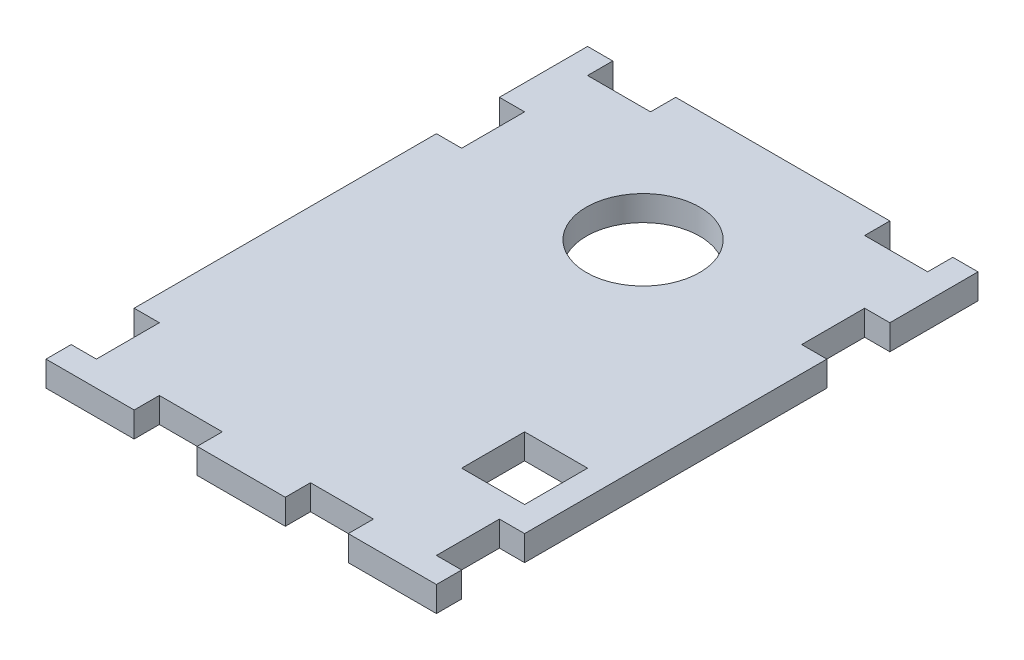
from build123d import *

# Parameters (mm, degrees)
SKETCH1_W           = 31
SKETCH1_H           = 43
BOSS_EXTRUDE1_DEPTH = 2
SKETCH2_W           = 5
SKETCH2_H           = 2
CUT_EXTRUDE1_DEPTH  = 2
SKETCH3_R           = 4.5
SKETCH3_W           = 5
SKETCH3_H           = 5
SKETCH3_W_2         = 2
SKETCH3_H_2         = 2
CUT_EXTRUDE2_DEPTH  = 2


with BuildPart() as part:
    # Sketch1 → Boss-Extrude1 (new body)
    with BuildSketch(Plane(origin=(0, 0, 0), x_dir=(1, 0, 0), z_dir=(0, 1, 0))):
        Rectangle(SKETCH1_W, SKETCH1_H)
    extrude(amount=BOSS_EXTRUDE1_DEPTH)

    # Sketch2 → Cut-Extrude1 (cut)
    with BuildSketch(Plane(origin=(0, 2, 0), x_dir=(1, 0, 0), z_dir=(0, 1, 0))):
        with Locations((11, 20.5)):
            Rectangle(SKETCH2_W, SKETCH2_H)
        with Locations((-11, 20.5)):
            Rectangle(SKETCH2_W, SKETCH2_H)
    extrude(amount=-CUT_EXTRUDE1_DEPTH, mode=Mode.SUBTRACT)

    # Sketch3 → Cut-Extrude2 (cut)
    with BuildSketch(Plane(origin=(0, 2, 0), x_dir=(1, 0, 0), z_dir=(0, 1, 0))):
        with Locations((0, 10.405013978)):
            Circle(SKETCH3_R)
        with Locations((11, -10)):
            Rectangle(SKETCH3_W, SKETCH3_H)
        with Locations((14.5, -17)):
            Rectangle(SKETCH3_W_2, SKETCH3_H)
        with Locations((6, -20.5)):
            Rectangle(SKETCH3_W, SKETCH3_H_2)
        with Locations((-14.5, -17)):
            Rectangle(SKETCH3_W_2, SKETCH3_H)
        with Locations((-6, -20.5)):
            Rectangle(SKETCH3_W, SKETCH3_H_2)
        with Locations((14.5, 12)):
            Rectangle(SKETCH3_W_2, SKETCH3_H)
        with Locations((-14.5, 12)):
            Rectangle(SKETCH3_W_2, SKETCH3_H)
    extrude(amount=-CUT_EXTRUDE2_DEPTH, mode=Mode.SUBTRACT)


solid = part.part
